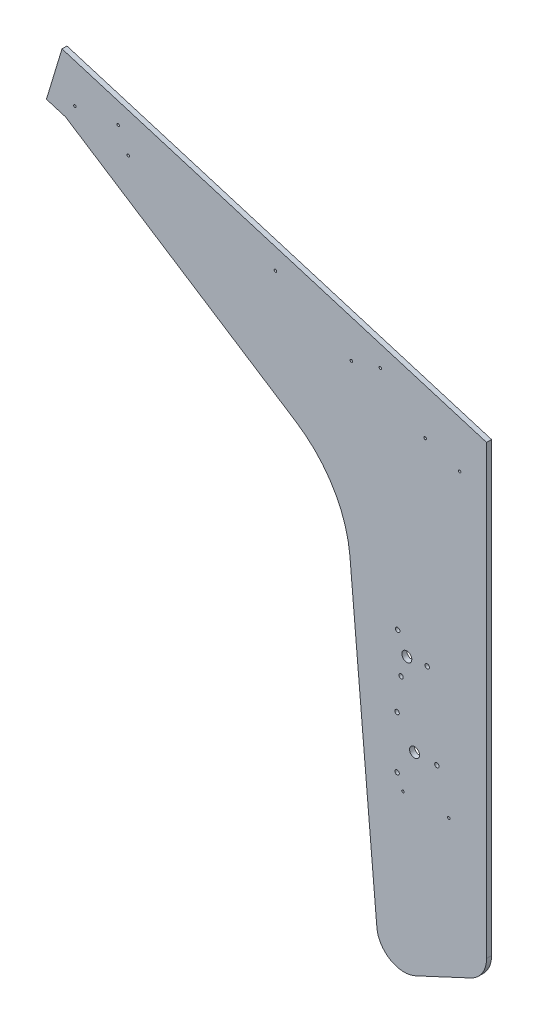
from build123d import *

# Parameters (mm, degrees)
BOSS_EXTRUDE1_DEPTH    = 6.35
F_10_CLEARANCE_HOLE1_D = 5.6134
SKETCH2_R              = 6.35
CUT_EXTRUDE1_DEPTH     = 7.35
HOLE1_D                = 3.175
HOLE1_DEPTH            = 31.75
HOLE1_CSINK_D          = 10.16
HOLE1_CSINK_ANGLE      = 82
HOLE1_TIP              = 0.953866233


with BuildPart() as part:
    # Sketch1 → Boss-Extrude1 (new body)
    with BuildSketch(Plane.XY):
        with BuildLine():
            Line((-35.929687435, 42.153790719), (-1.51387348, -351.220762831))
            ThreePointArc((-1.51387348, -351.220762831), (15.815726351, -378.422785743), (48.038169143, -379.829647978))
            Line((48.038169143, -379.829647978), (118.213861049, -347.106185426))
            ThreePointArc((118.213861049, -347.106185426), (132.909364503, -334.218574785), (138.378918258, -315.453385964))
            Line((138.378918258, -315.453385964), (138.378918258, 254.538122714))
            Line((138.378918258, 254.538122714), (-403.099057101, 418.419278389))
            Line((-403.099057101, 418.419278389), (-422.935039487, 352.879420938))
            Line((-422.935039487, 352.879420938), (-398.624090476, 345.521584423))
            Line((-398.624090476, 345.521584423), (-105.026598758, 156.030008008))
            ThreePointArc((-105.026598758, 156.030008008), (-57.378429325, 107.040440177), (-35.929687435, 42.153790719))
        make_face()
    extrude(amount=BOSS_EXTRUDE1_DEPTH)

    # #10 Clearance Hole1 (through all)
    with Locations(Plane(origin=(0, 0, 0), x_dir=(-1, 0, 0), z_dir=(0, 0, -1))):
        with Locations((-24.251683892, -100.351877226), (-24.251683892, -167.026877226), (-75.051683892, -133.689377226), (-29.317369668, -58.274702428), (-25.026257572, -9.227066735), (-62.648775204, -30.647052627)):
            Hole(F_10_CLEARANCE_HOLE1_D / 2)

    # Sketch2 → Cut-Extrude1 (cut, through all)
    with BuildSketch(Plane(origin=(0, 0, 0), x_dir=(-1, 0, 0), z_dir=(0, 0, -1))):
        with Locations((-46.476683892, -133.689377226)):
            Circle(SKETCH2_R)
        with Locations((-36.66056812, -32.920726132)):
            Circle(SKETCH2_R)
    extrude(amount=-CUT_EXTRUDE1_DEPTH, mode=Mode.SUBTRACT)

    # Hole1
    with Locations(Plane(origin=(277.286738577, -215.287141225, 12.7), x_dir=(-0.089959629, 0.995945413, 0), z_dir=(0, 0, 1))):
        with Locations((637.870011036, 553.595098153), (52.960474705, 241.752641108), (47.697836423, 183.489834462), (434.459074831, 134.806234549), (453.103621196, 177.188747915), (499.723341091, 267.496267453), (636.071223534, 609.111420407), (609.449424187, 543.22015483), (559.371199386, 359.303721429), (507.038658285, 229.776136946)):
            CounterSinkHole(HOLE1_D / 2, HOLE1_CSINK_D / 2, depth=HOLE1_DEPTH, counter_sink_angle=HOLE1_CSINK_ANGLE)
            with Locations((0, 0, -(HOLE1_DEPTH + HOLE1_TIP / 2))):  # 118° drill point
                Cone(0, HOLE1_D / 2, HOLE1_TIP, mode=Mode.SUBTRACT)


solid = part.part
